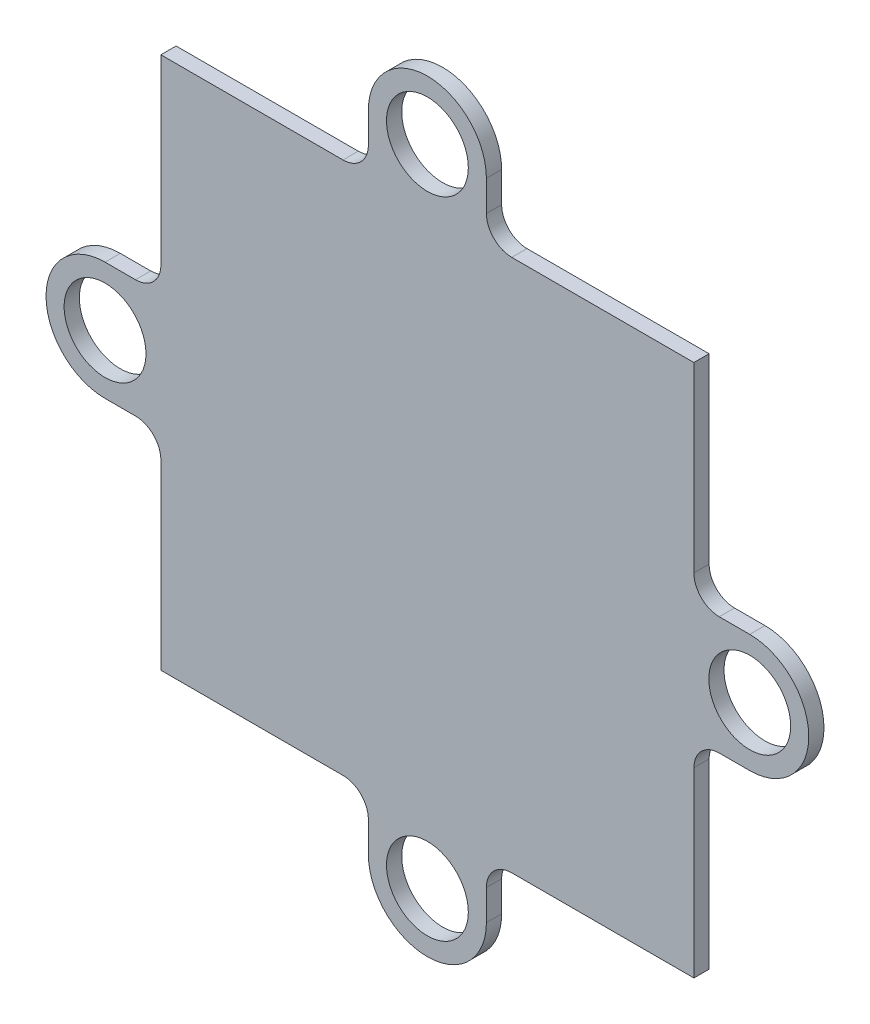
from build123d import *

# Parameters (mm, degrees)
SKETCH1_R           = 3.225
BOSS_EXTRUDE1_DEPTH = 1.2


with BuildPart() as part:
    # Sketch1 → Boss-Extrude1 (new body)
    with BuildSketch(Plane.XY):
        with BuildLine():
            ThreePointArc((4.65, 25.4), (0, 30.05), (-4.65, 25.4))
            Line((-4.65, 25.4), (-4.65, 23))
            ThreePointArc((-4.65, 23), (-5.235786438, 21.585786438), (-6.65, 21))
            Line((-6.65, 21), (-8.759132098, 21))
            Line((-8.759132098, 21), (-21, 21))
            Line((-21, 21), (-21, 7.133487824))
            Line((-21, 7.133487824), (-21, 6.65))
            ThreePointArc((-21, 6.65), (-21.585786438, 5.235786438), (-23, 4.65))
            Line((-23, 4.65), (-25.4, 4.65))
            ThreePointArc((-25.4, 4.65), (-30.05, 0), (-25.4, -4.65))
            Line((-25.4, -4.65), (-23, -4.65))
            ThreePointArc((-23, -4.65), (-21.585786438, -5.235786438), (-21, -6.65))
            Line((-21, -6.65), (-21, -8.759132098))
            Line((-21, -8.759132098), (-21, -21))
            Line((-21, -21), (-7.133487824, -21))
            Line((-7.133487824, -21), (-6.65, -21))
            ThreePointArc((-6.65, -21), (-5.235786438, -21.585786438), (-4.65, -23))
            Line((-4.65, -23), (-4.65, -25.4))
            ThreePointArc((-4.65, -25.4), (0, -30.05), (4.65, -25.4))
            Line((4.65, -25.4), (4.65, -23))
            ThreePointArc((4.65, -23), (5.235786438, -21.585786438), (6.65, -21))
            Line((6.65, -21), (8.759132098, -21))
            Line((8.759132098, -21), (21, -21))
            Line((21, -21), (21, -7.133487824))
            Line((21, -7.133487824), (21, -6.65))
            ThreePointArc((21, -6.65), (21.585786438, -5.235786438), (23, -4.65))
            Line((23, -4.65), (25.4, -4.65))
            ThreePointArc((25.4, -4.65), (30.05, 0), (25.4, 4.65))
            Line((25.4, 4.65), (23, 4.65))
            ThreePointArc((23, 4.65), (21.585786438, 5.235786438), (21, 6.65))
            Line((21, 6.65), (21, 8.759132098))
            Line((21, 8.759132098), (21, 21))
            Line((21, 21), (7.133487824, 21))
            Line((7.133487824, 21), (6.65, 21))
            ThreePointArc((6.65, 21), (5.235786438, 21.585786438), (4.65, 23))
            Line((4.65, 23), (4.65, 25.4))
        make_face()
        with Locations((0, -25.4)):
            Circle(SKETCH1_R, mode=Mode.SUBTRACT)
        with Locations((25.4, 0)):
            Circle(SKETCH1_R, mode=Mode.SUBTRACT)
        with Locations((-25.4, 0)):
            Circle(SKETCH1_R, mode=Mode.SUBTRACT)
        with Locations((0, 25.4)):
            Circle(SKETCH1_R, mode=Mode.SUBTRACT)
    extrude(amount=BOSS_EXTRUDE1_DEPTH)


solid = part.part
